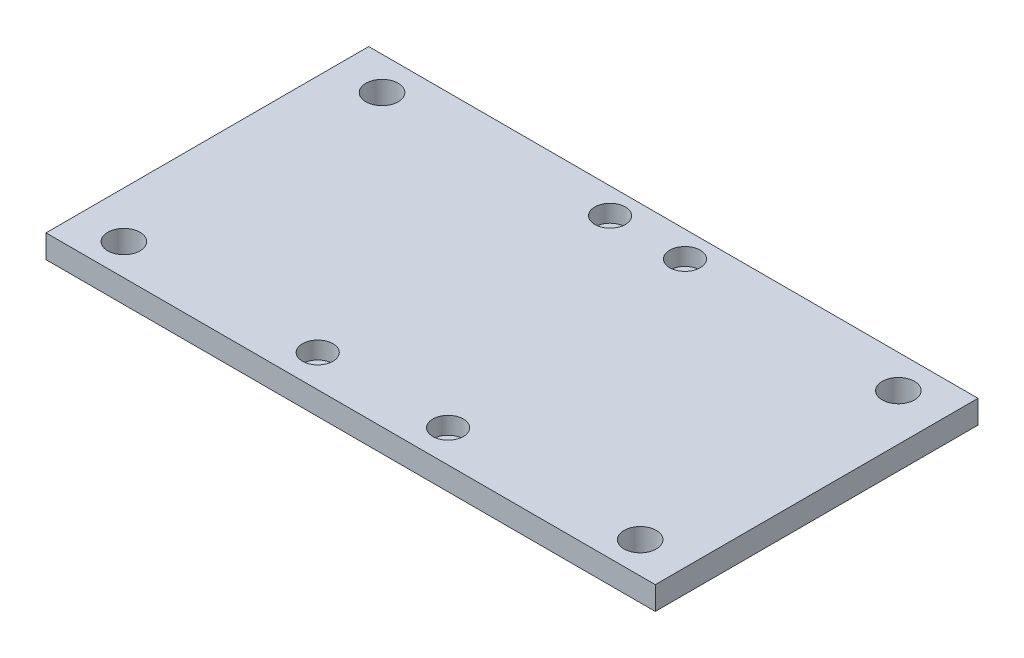
from build123d import *

# Parameters (mm, degrees)
SKETCH1_W                                            = 119.888
SKETCH1_H                                            = 63.5
BOSS_EXTRUDE1_DEPTH                                  = 4.572
CBORE_FOR_M3_HEXAGON_SOCKET_HEAD_CAP_SCR_D           = 3.4
CBORE_FOR_M3_HEXAGON_SOCKET_HEAD_CAP_SCR_CBORE_D     = 6
CBORE_FOR_M3_HEXAGON_SOCKET_HEAD_CAP_SCR_CBORE_DEPTH = 3.4
SKETCH5_R                                            = 3.175
CUT_EXTRUDE1_DEPTH                                   = 5.572


with BuildPart() as part:
    # Sketch1 → Boss-Extrude1 (new body)
    with BuildSketch(Plane(origin=(0, 0, 0), x_dir=(1, 0, 0), z_dir=(0, 1, 0))):
        Rectangle(SKETCH1_W, SKETCH1_H)
    extrude(amount=BOSS_EXTRUDE1_DEPTH)

    # CBORE for M3 Hexagon socket head cap screws1 (through all)
    with Locations(Plane(origin=(0, 4.572, 0), x_dir=(1, 0, 0), z_dir=(0, 1, 0))):
        with Locations((7.366, 26.67), (12.827, -25.4), (-12.827, -25.4), (-7.366, 26.67)):
            CounterBoreHole(CBORE_FOR_M3_HEXAGON_SOCKET_HEAD_CAP_SCR_D / 2, CBORE_FOR_M3_HEXAGON_SOCKET_HEAD_CAP_SCR_CBORE_D / 2, CBORE_FOR_M3_HEXAGON_SOCKET_HEAD_CAP_SCR_CBORE_DEPTH)

    # Sketch5 → Cut-Extrude1 (cut, through all)
    with BuildSketch(Plane(origin=(0, 4.572, 0), x_dir=(1, 0, 0), z_dir=(0, 1, 0))):
        with Locations((50.8, 25.225713352)):
            Circle(SKETCH5_R)
        with Locations((50.8, -25.574286648)):
            Circle(SKETCH5_R)
        with Locations((-50.8, 25.225713352)):
            Circle(SKETCH5_R)
        with Locations((-50.8, -25.574286648)):
            Circle(SKETCH5_R)
    extrude(amount=-CUT_EXTRUDE1_DEPTH, mode=Mode.SUBTRACT)


solid = part.part
